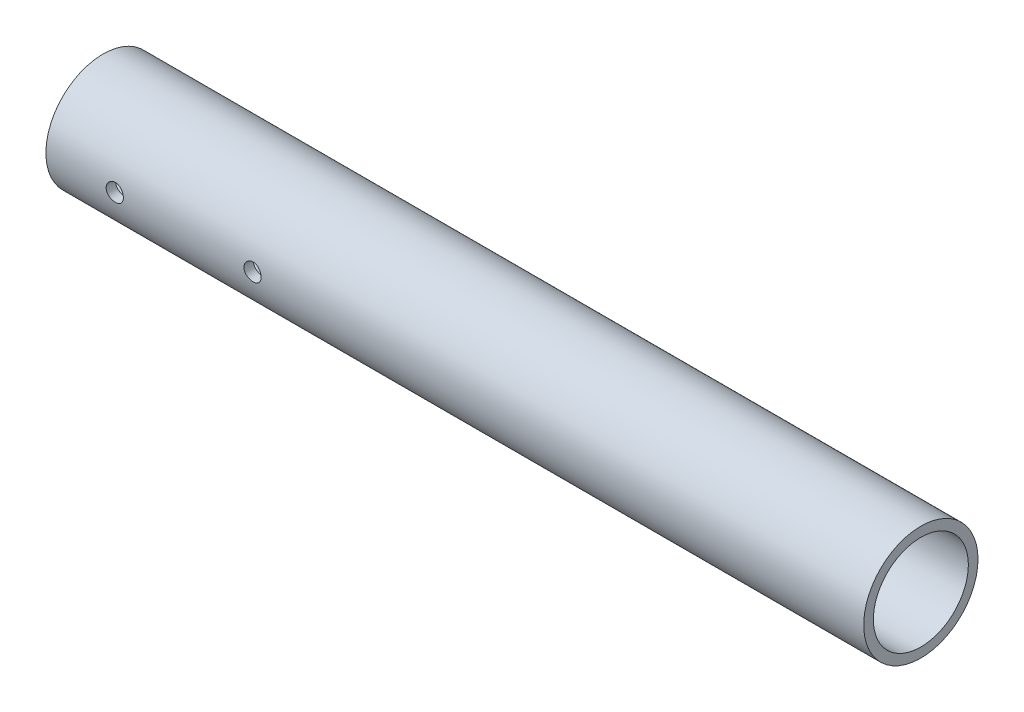
from build123d import *

# Parameters (mm, degrees)
SKETCH1_R                = 21.082
SKETCH1_R_2              = 17.526
BOSS_EXTRUDE1_DEPTH      = 127
BOSS_EXTRUDE1_DEPTH_BACK = 174.625
SKETCH2_R                = 3.175
CUT_EXTRUDE1_DEPTH       = 22.082
CUT_EXTRUDE1_DEPTH_BACK  = 22.082


with BuildPart() as part:
    # Sketch1 → Boss-Extrude1 (new body, two sides)
    with BuildSketch(Plane(origin=(0, 0, 0), x_dir=(0, 0, -1), z_dir=(1, 0, 0))) as boss_extrude1_sk:
        Circle(SKETCH1_R)
        Circle(SKETCH1_R_2, mode=Mode.SUBTRACT)
    extrude(amount=BOSS_EXTRUDE1_DEPTH)
    extrude(boss_extrude1_sk.sketch, amount=-BOSS_EXTRUDE1_DEPTH_BACK)

    # Sketch2 → Cut-Extrude1 (cut, two sides)
    with BuildSketch(Plane.XY) as cut_extrude1_sk:
        with Locations((-98.425, 0)):
            Circle(SKETCH2_R)
        with Locations((-149.225, 0)):
            Circle(SKETCH2_R)
    extrude(amount=CUT_EXTRUDE1_DEPTH, mode=Mode.SUBTRACT)
    extrude(cut_extrude1_sk.sketch, amount=-CUT_EXTRUDE1_DEPTH_BACK, mode=Mode.SUBTRACT)


solid = part.part
